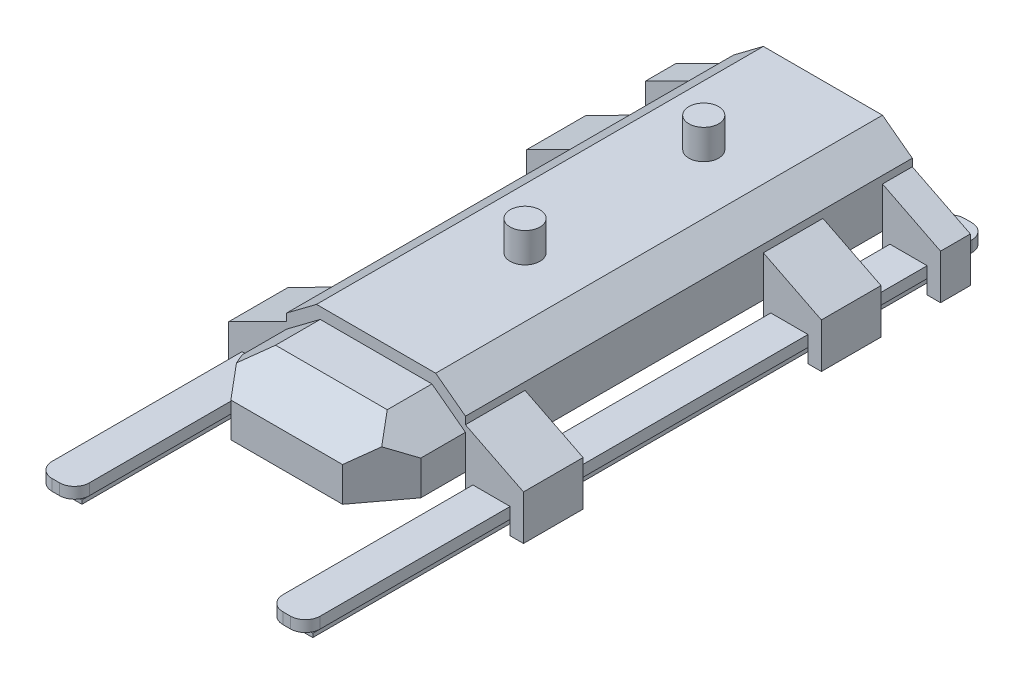
from build123d import *

# Parameters (mm, degrees)
BOSS_EXTRUDE1_DEPTH      = 381
SKETCH3_W                = 98.988046958
SKETCH3_H                = 406.4
SKETCH3_H_2              = 101.6
CUT_EXTRUDE1_DEPTH       = 121.65
CUT_EXTRUDE1_DEPTH_BACK  = 57.038415052
BOSS_EXTRUDE2_DEPTH      = 152.4
CUT_EXTRUDE2_DEPTH       = 252.388046958
CUT_EXTRUDE2_DEPTH_BACK  = 1
CUT_EXTRUDE3_DEPTH       = 121.65
CUT_EXTRUDE3_DEPTH_BACK  = 57.038415052
SKETCH8_W                = 63.5
SKETCH8_H                = 19.05
BOSS_EXTRUDE3_DEPTH      = 730.25
BOSS_EXTRUDE3_DEPTH_BACK = 431.8
FILLET1_R                = 25.4
BOSS_EXTRUDE4_DEPTH      = 704.85
BOSS_EXTRUDE4_DEPTH_BACK = 406.4
SKETCH10_R               = 25.4
BOSS_EXTRUDE5_DEPTH      = 50.8


with BuildPart() as part:
    # Sketch2 → Boss-Extrude1 (new body, symmetric)
    with BuildSketch(Plane.XY):
        Polygon((152.4, 0), (0, 0), (0, 120.65), (101.6, 120.65), (152.4, 82.55), (152.4, 69.85), (251.388046958, 20.161584948), (251.388046958, -56.038415052), (228.6, -56.038415052), (228.6, -12.7), (165.1, -12.7), (165.1, -50.8), (152.4, -50.8), align=None)
    extrude(amount=BOSS_EXTRUDE1_DEPTH, both=True)

    # Sketch3 → Cut-Extrude1 (cut, two sides)
    with BuildSketch(Plane(origin=(0, 0, 0), x_dir=(1, 0, 0), z_dir=(0, 1, 0))) as cut_extrude1_sk:
        with Locations((201.894023479, -76.2)):
            Rectangle(SKETCH3_W, SKETCH3_H)
        with Locations((201.894023479, 279.4)):
            Rectangle(SKETCH3_W, SKETCH3_H_2)
    extrude(amount=CUT_EXTRUDE1_DEPTH, mode=Mode.SUBTRACT)
    extrude(cut_extrude1_sk.sketch, amount=-CUT_EXTRUDE1_DEPTH_BACK, mode=Mode.SUBTRACT)

    # Sketch4 → Boss-Extrude2 (add)
    with BuildSketch(Plane.XY.offset(381)):
        Polygon((152.4, 0), (0, 0), (0, 101.6), (95.25, 101.6), (152.4, 58.7375), align=None)
    extrude(amount=BOSS_EXTRUDE2_DEPTH)

    # Sketch6 → Cut-Extrude2 (cut, two sides)
    with BuildSketch(Plane(origin=(0, 0, 0), x_dir=(0, 0, -1), z_dir=(1, 0, 0))) as cut_extrude2_sk:
        Polygon((-533.4, 101.6), (-533.4, 58.7375), (-457.2, 101.6), align=None)
    extrude(amount=CUT_EXTRUDE2_DEPTH, mode=Mode.SUBTRACT)
    extrude(cut_extrude2_sk.sketch, amount=-CUT_EXTRUDE2_DEPTH_BACK, mode=Mode.SUBTRACT)

    # Sketch7 → Cut-Extrude3 (cut, two sides)
    with BuildSketch(Plane(origin=(0, 0, 0), x_dir=(1, 0, 0), z_dir=(0, 1, 0))) as cut_extrude3_sk:
        Polygon((152.4, -533.4), (152.4, -457.2), (95.25, -533.4), align=None)
    extrude(amount=CUT_EXTRUDE3_DEPTH, mode=Mode.SUBTRACT)
    extrude(cut_extrude3_sk.sketch, amount=-CUT_EXTRUDE3_DEPTH_BACK, mode=Mode.SUBTRACT)

    # Mirror1: part across plane


with BuildPart() as part_1:
    add(part.part)
    add(part.part.mirror(Plane(origin=(0, 0, 0), x_dir=(0, 0, 1), z_dir=(1, 0, 0))))

    # Sketch8 → Boss-Extrude3 (add, two sides)
    with BuildSketch(Plane.XY) as boss_extrude3_sk:
        with Locations((-196.85, -22.225)):
            Rectangle(SKETCH8_W, SKETCH8_H)
        with Locations((196.85, -22.225)):
            Rectangle(SKETCH8_W, SKETCH8_H)
    extrude(amount=BOSS_EXTRUDE3_DEPTH)
    extrude(boss_extrude3_sk.sketch, amount=-BOSS_EXTRUDE3_DEPTH_BACK)

    # Fillet1
    fillet1_edges = [part_1.edges().sort_by_distance(p)[0] for p in [
        (-165.1, -22.225, 730.25),
        (-228.6, -22.225, 730.25),
        (-228.6, -22.225, -431.8),
        (-165.1, -22.225, -431.8),
        (228.6, -22.225, 730.25),
        (165.1, -22.225, 730.25),
        (165.1, -22.225, -431.8),
        (228.6, -22.225, -431.8),
    ]]
    fillet(fillet1_edges, radius=FILLET1_R)

    # Sketch9 → Boss-Extrude4 (add, two sides)
    with BuildSketch(Plane.XY) as boss_extrude4_sk:
        Polygon((177.8, -50.8), (215.9, -50.8), (215.9, -44.45), (209.55, -44.45), (209.55, -31.75), (184.15, -31.75), (184.15, -44.45), (177.8, -44.45), align=None)
        Polygon((-184.15, -44.45), (-184.15, -31.75), (-209.55, -31.75), (-209.55, -44.45), (-215.9, -44.45), (-215.9, -50.8), (-177.8, -50.8), (-177.8, -44.45), align=None)
    extrude(amount=BOSS_EXTRUDE4_DEPTH)
    extrude(boss_extrude4_sk.sketch, amount=-BOSS_EXTRUDE4_DEPTH_BACK)

    # Sketch10 → Boss-Extrude5 (add)
    with BuildSketch(Plane(origin=(0, 120.65, 0), x_dir=(1, 0, 0), z_dir=(0, 1, 0))):
        with Locations((0, 177.8)):
            Circle(SKETCH10_R)
        with Locations((0, -127)):
            Circle(SKETCH10_R)
    extrude(amount=BOSS_EXTRUDE5_DEPTH)


solid = part_1.part
